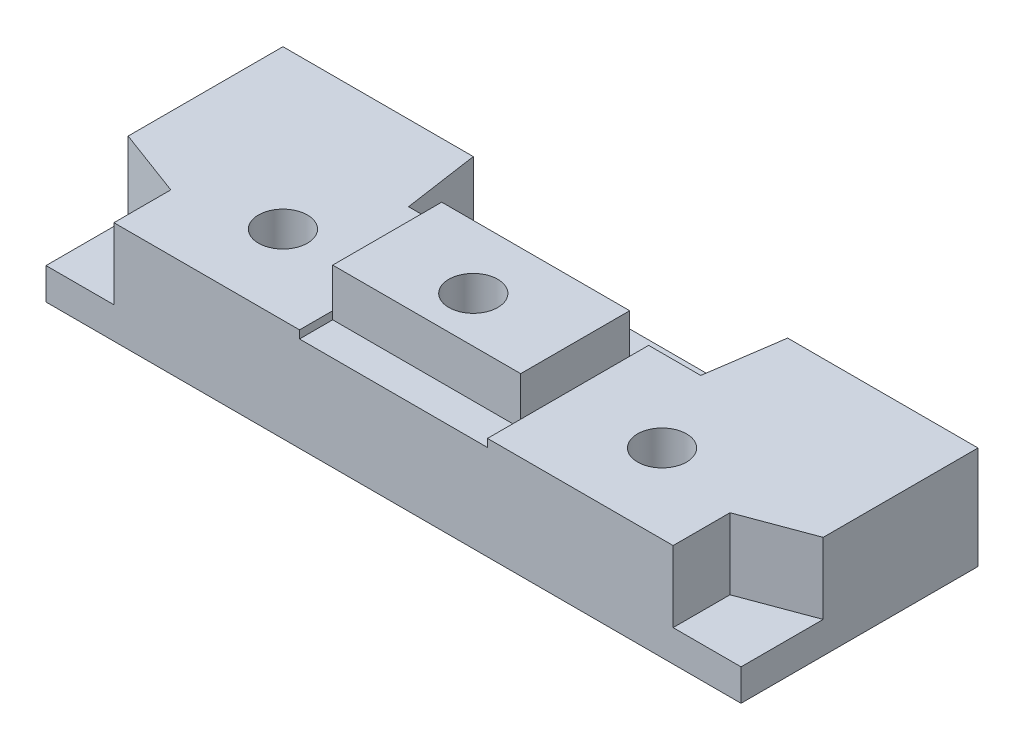
from build123d import *

# Parameters (mm, degrees)
SKETCH1_W           = 44
SKETCH1_H           = 15
BOSS_EXTRUDE1_DEPTH = 5
SKETCH2_W           = 11.9
SKETCH2_H           = 15
BOSS_EXTRUDE2_DEPTH = 4
SKETCH3_R           = 1.55
CUT_EXTRUDE1_DEPTH  = 3
SKETCH4_R           = 1.55
CUT_EXTRUDE2_DEPTH  = 3
CUT_EXTRUDE3_DEPTH  = 3
SKETCH7_W           = 11.9
SKETCH7_H           = 6
CUT_EXTRUDE4_DEPTH  = 7
SKETCH8_W           = 11.9
SKETCH8_H           = 2.1
CUT_EXTRUDE5_DEPTH  = 3
SKETCH9_R           = 1.55
BOSS_EXTRUDE4_DEPTH = 1.5


with BuildPart() as part:
    # Sketch1 → Boss-Extrude1 (new body)
    with BuildSketch(Plane(origin=(0, 0, 0), x_dir=(1, 0, 0), z_dir=(0, 1, 0))):
        with Locations((22, -7.5)):
            Rectangle(SKETCH1_W, SKETCH1_H)
    extrude(amount=BOSS_EXTRUDE1_DEPTH)

    # Sketch2 → Boss-Extrude2 (add)
    with BuildSketch(Plane(origin=(0, 5, 0), x_dir=(1, 0, 0), z_dir=(0, 1, 0))):
        with Locations((22, -7.5)):
            Rectangle(SKETCH2_W, SKETCH2_H)
    extrude(amount=BOSS_EXTRUDE2_DEPTH)

    # Sketch3 → Cut-Extrude1 (cut)
    with BuildSketch(Plane(origin=(0, 5, 0), x_dir=(1, 0, 0), z_dir=(0, 1, 0))):
        with Locations((10, -10)):
            Circle(SKETCH3_R)
        with Locations((34, -10)):
            Circle(SKETCH3_R)
    extrude(amount=-CUT_EXTRUDE1_DEPTH, mode=Mode.SUBTRACT)

    # Sketch4 → Cut-Extrude2 (cut)
    with BuildSketch(Plane(origin=(0, 9, 0), x_dir=(1, 0, 0), z_dir=(0, 1, 0))):
        with Locations((22.05, -10)):
            Circle(SKETCH4_R)
    extrude(amount=-CUT_EXTRUDE2_DEPTH, mode=Mode.SUBTRACT)

    # Sketch6 → Cut-Extrude3 (cut)
    with BuildSketch(Plane(origin=(0, 5, 0), x_dir=(1, 0, 0), z_dir=(0, 1, 0))):
        Polygon((16.05, -4.8), (12.75, -4.8), (12.05, 0), (16.05, 0), align=None)
        Polygon((0, -15), (4.3, -15), (4.3, -11.4), (0, -9.8), align=None)
        Polygon((39.7, -11.4), (44, -9.8), (44, -15), (39.7, -15), align=None)
        Polygon((31.95, 0), (27.95, 0), (27.95, -4.8), (31.25, -4.8), align=None)
    extrude(amount=-CUT_EXTRUDE3_DEPTH, mode=Mode.SUBTRACT)

    # Sketch7 → Cut-Extrude4 (cut)
    with BuildSketch(Plane(origin=(0, 9, 0), x_dir=(1, 0, 0), z_dir=(0, 1, 0))):
        with Locations((22, -3)):
            Rectangle(SKETCH7_W, SKETCH7_H)
    extrude(amount=-CUT_EXTRUDE4_DEPTH, mode=Mode.SUBTRACT)

    # Sketch8 → Cut-Extrude5 (cut)
    with BuildSketch(Plane(origin=(0, 9, 0), x_dir=(1, 0, 0), z_dir=(0, 1, 0))):
        with Locations((22, -13.95)):
            Rectangle(SKETCH8_W, SKETCH8_H)
    extrude(amount=-CUT_EXTRUDE5_DEPTH, mode=Mode.SUBTRACT)

    # Sketch9 → Boss-Extrude4 (add)
    with BuildSketch(Plane(origin=(0, 5, 0), x_dir=(1, 0, 0), z_dir=(0, 1, 0))):
        Polygon((0, 0), (12.05, 0), (12.75, -4.8), (16.05, -4.8), (16.05, -15), (4.3, -15), (4.3, -11.4), (0, -9.8), align=None)
        with Locations((10, -10)):
            Circle(SKETCH9_R, mode=Mode.SUBTRACT)
        Polygon((39.7, -11.4), (44, -9.8), (44, 0), (31.95, 0), (31.25, -4.8), (27.95, -4.8), (27.95, -15), (39.7, -15), align=None)
        with Locations((34, -10)):
            Circle(SKETCH9_R, mode=Mode.SUBTRACT)
    extrude(amount=BOSS_EXTRUDE4_DEPTH)


solid = part.part
